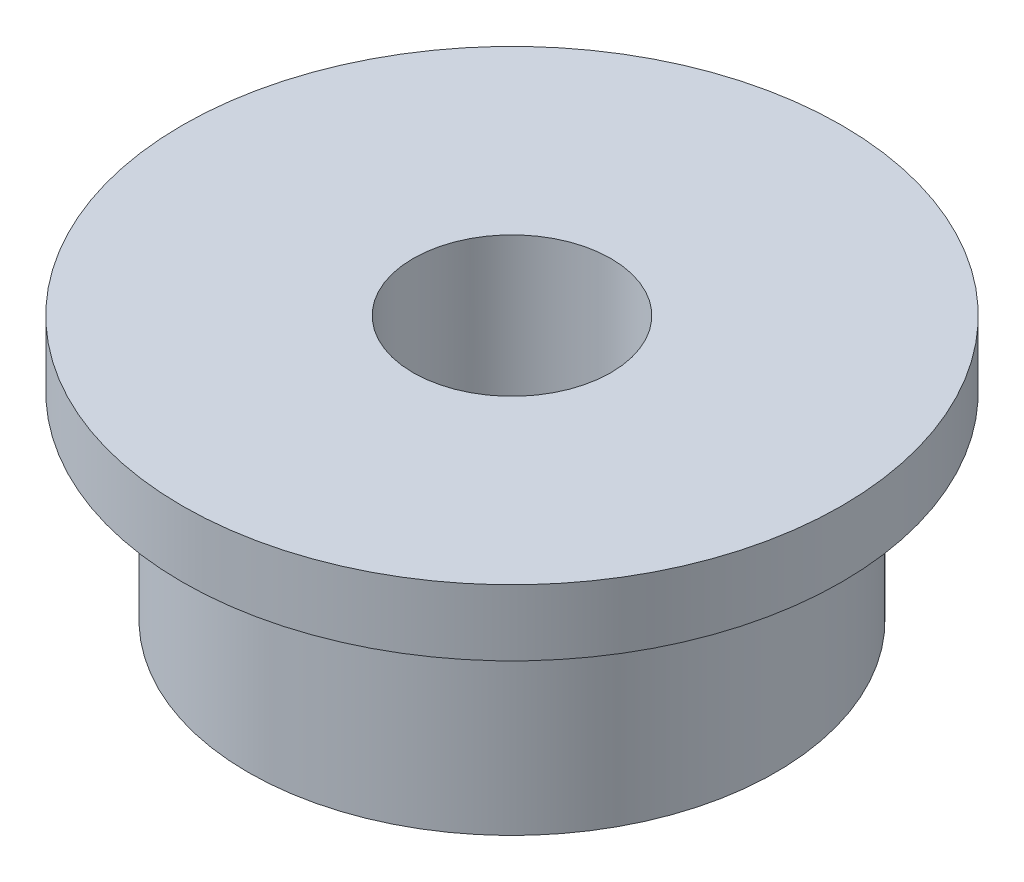
from build123d import *

# Parameters (mm, degrees)
SKETCH1_R           = 5
BOSS_EXTRUDE1_DEPTH = 1
SKETCH2_R           = 4
BOSS_EXTRUDE2_DEPTH = 3
SKETCH3_R           = 1.5
CUT_EXTRUDE1_DEPTH  = 13


with BuildPart() as part:
    # Sketch1 → Boss-Extrude1 (new body)
    with BuildSketch(Plane(origin=(0, 0, 0), x_dir=(1, 0, 0), z_dir=(0, 1, 0))):
        Circle(SKETCH1_R)
    extrude(amount=BOSS_EXTRUDE1_DEPTH)

    # Sketch2 → Boss-Extrude2 (add)
    with BuildSketch(Plane.XZ):
        Circle(SKETCH2_R)
    extrude(amount=BOSS_EXTRUDE2_DEPTH)

    # Sketch3 → Cut-Extrude1 (cut)
    with BuildSketch(Plane.XZ.offset(3)):
        Circle(SKETCH3_R)
    extrude(amount=-CUT_EXTRUDE1_DEPTH, mode=Mode.SUBTRACT)


solid = part.part
